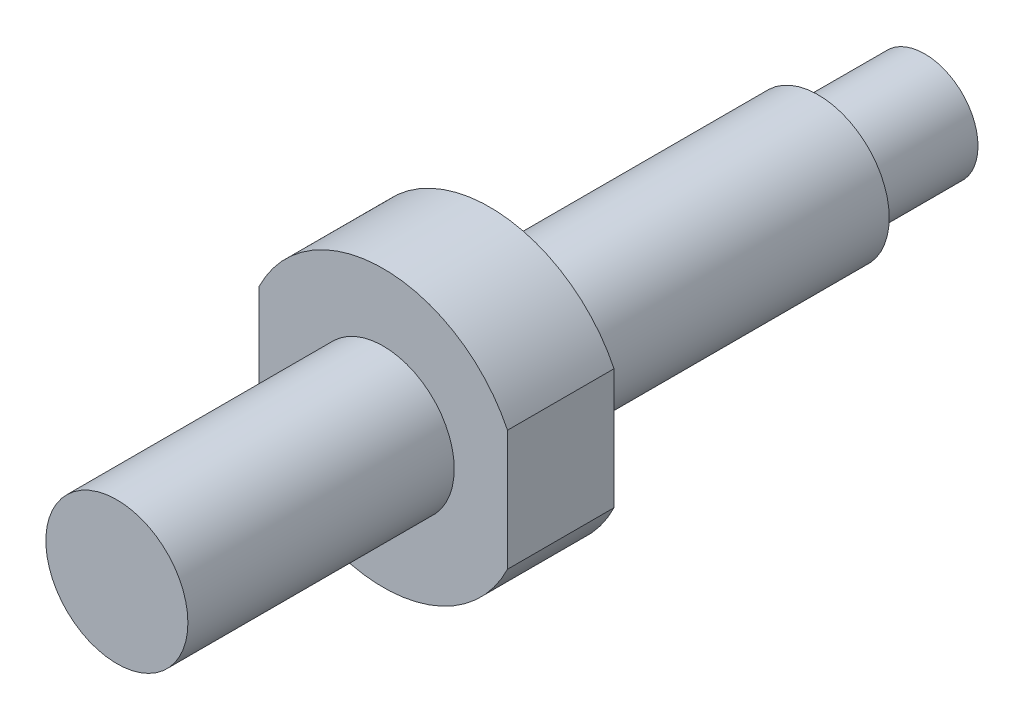
from build123d import *

# Parameters (mm, degrees)
SKETCH_3_W          = 8
SKETCH_3_H          = 16.823898374
CUT_EXTRUDE_1_DEPTH = 10
SKETCH_5_OUTSIDE_W  = 25.122
SKETCH_5_OUTSIDE_H  = 29.122
SKETCH_5_OUTSIDE_R  = 7.77784742
CUT_EXTRUDE_2_DEPTH = 10
SKETCH_6_R          = 3
EXTRUDE_1_DEPTH     = 6


with BuildPart() as part:
    # 草图2 → 旋转1 (revolve)
    with BuildSketch(Plane(origin=(0, 0, 0), x_dir=(0, 0, -1), z_dir=(1, 0, 0))):
        Polygon((0, 0), (0, 4), (15, 4), (15, 9), (21, 9), (21, 4), (39.5, 4), (39.5, 0), align=None)
    revolve(axis=Axis((0, 0, 0), (0, 0, -1)))

    # 草图3 → 切除-拉伸1 (cut)
    with BuildSketch(Plane.XY.offset(-15)):
        with Locations((-11, -0.026043186)):
            Rectangle(SKETCH_3_W, SKETCH_3_H)
        with Locations((11, -0.026043186)):
            Rectangle(SKETCH_3_W, SKETCH_3_H)
    extrude(amount=-CUT_EXTRUDE_1_DEPTH, mode=Mode.SUBTRACT)

    # 草图5 outside → 切除-拉伸2 (cut)
    with BuildSketch(Plane(origin=(0, 0, -21), x_dir=(-1, 0, 0), z_dir=(0, 0, -1))):
        Rectangle(SKETCH_5_OUTSIDE_W, SKETCH_5_OUTSIDE_H)
        Circle(SKETCH_5_OUTSIDE_R, mode=Mode.SUBTRACT)
    extrude(amount=-CUT_EXTRUDE_2_DEPTH, mode=Mode.SUBTRACT)

    # 草图6 → 凸台-拉伸1 (add)
    with BuildSketch(Plane(origin=(0, 0, -39.5), x_dir=(-1, 0, 0), z_dir=(0, 0, -1))):
        Circle(SKETCH_6_R)
    extrude(amount=EXTRUDE_1_DEPTH)


solid = part.part
